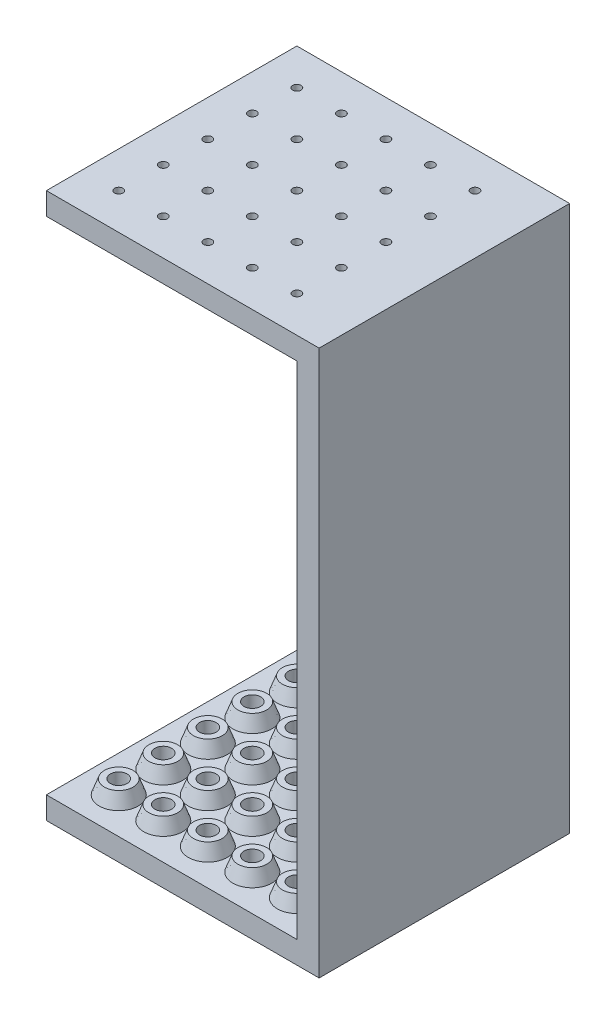
from build123d import *

# Parameters (mm, degrees)
SKETCH1_W            = 24.5
SKETCH1_H            = 22.5
BOSS_EXTRUDE1_DEPTH  = 2
SKETCH2_W            = 2
SKETCH2_H            = 22.5
BOSS_EXTRUDE2_DEPTH  = 45
SKETCH4_W            = 24.5
SKETCH4_H            = 22.5
BOSS_EXTRUDE3_DEPTH  = 2
SKETCH3_R            = 0.375
CUT_EXTRUDE1_DEPTH   = 50
SKETCH5_R            = 1.75
BOSS_EXTRUDE4_DEPTH  = 1.25
BOSS_EXTRUDE4_TAPER  = 20
SKETCH6_R            = 0.75
CUT_EXTRUDE2_DEPTH   = 1.25
LPATTERN1_COUNT      = 5
LPATTERN1_PITCH      = 4
LPATTERN1_COUNT_DIR2 = 5
LPATTERN1_PITCH_DIR2 = 4


with BuildPart() as part:
    # Sketch1 → Boss-Extrude1 (new body)
    with BuildSketch(Plane(origin=(0, 0, 0), x_dir=(1, 0, 0), z_dir=(0, 1, 0))):
        Rectangle(SKETCH1_W, SKETCH1_H)
    extrude(amount=BOSS_EXTRUDE1_DEPTH)

    # Sketch2 → Boss-Extrude2 (add)
    with BuildSketch(Plane(origin=(0, 2, 0), x_dir=(1, 0, 0), z_dir=(0, 1, 0))):
        with Locations((11.25, 0)):
            Rectangle(SKETCH2_W, SKETCH2_H)
    extrude(amount=BOSS_EXTRUDE2_DEPTH)

    # Sketch4 → Boss-Extrude3 (add)
    with BuildSketch(Plane(origin=(0, 47, 0), x_dir=(1, 0, 0), z_dir=(0, 1, 0))):
        Rectangle(SKETCH4_W, SKETCH4_H)
    extrude(amount=BOSS_EXTRUDE3_DEPTH)

    # Sketch3 → Cut-Extrude1 (cut, through all)
    with BuildSketch(Plane.XZ):
        with Locations((-9, 8)):
            Circle(SKETCH3_R)
    cut_extrude1 = extrude(amount=-CUT_EXTRUDE1_DEPTH, mode=Mode.SUBTRACT)

    # Sketch5 → Boss-Extrude4 (add)
    with BuildSketch(Plane(origin=(0, 2, 0), x_dir=(1, 0, 0), z_dir=(0, 1, 0))):
        with Locations((-9, -8)):
            Circle(SKETCH5_R)
    boss_extrude4 = extrude(amount=BOSS_EXTRUDE4_DEPTH, taper=BOSS_EXTRUDE4_TAPER)

    # Sketch6 → Cut-Extrude2 (cut)
    with BuildSketch(Plane(origin=(0, 3.25, 0), x_dir=(1, 0, 0), z_dir=(0, 1, 0))):
        with Locations((-9, -8)):
            Circle(SKETCH6_R)
    cut_extrude2 = extrude(amount=-CUT_EXTRUDE2_DEPTH, mode=Mode.SUBTRACT)

    # LPattern1: Cut-Extrude1, Boss-Extrude4, Cut-Extrude2 5 × 5
    with Locations(*[(j * LPATTERN1_PITCH_DIR2, 0, -i * LPATTERN1_PITCH) for i in range(LPATTERN1_COUNT) for j in range(LPATTERN1_COUNT_DIR2) if (i, j) != (0, 0)]):
        add(cut_extrude1, mode=Mode.SUBTRACT)
        add(boss_extrude4)
        add(cut_extrude2, mode=Mode.SUBTRACT)


solid = part.part
